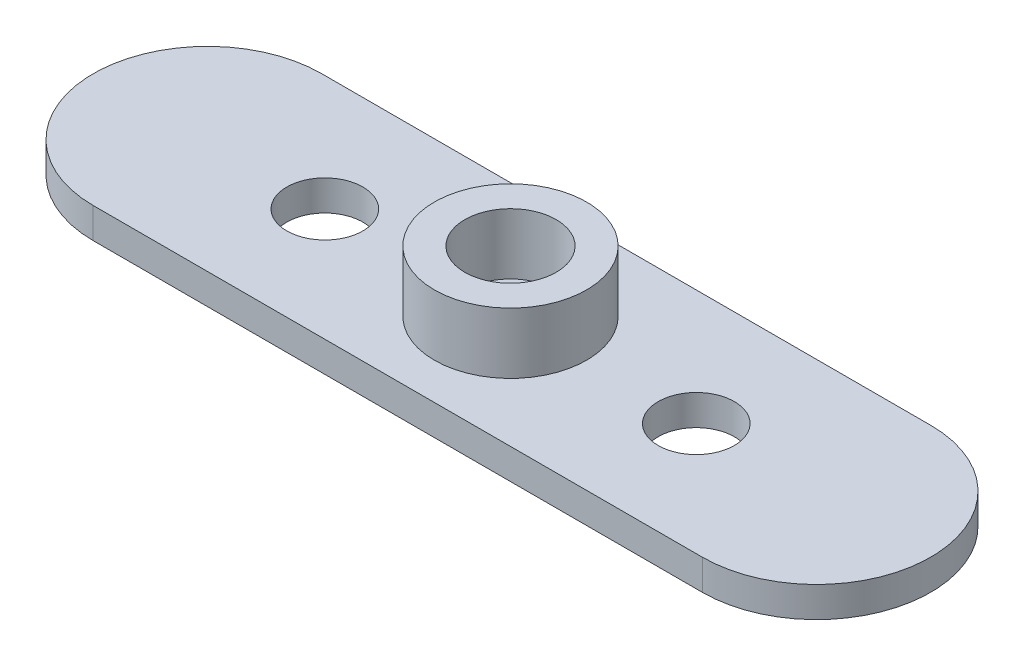
from build123d import *

# Parameters (mm, degrees)
BOSS_EXTRUDE1_DEPTH = 2
SKETCH2_R           = 5
BOSS_EXTRUDE3_DEPTH = 4
SKETCH5_R           = 3
CUT_EXTRUDE1_DEPTH  = 4
SKETCH6_R           = 1.5
CUT_EXTRUDE2_DEPTH  = 2
SKETCH8_R           = 2.5
CUT_EXTRUDE3_DEPTH  = 3
SKETCH7_R           = 2.5
CUT_EXTRUDE4_DEPTH  = 3


with BuildPart() as part:
    # Sketch1 → Boss-Extrude1 (new body)
    with BuildSketch(Plane(origin=(0, 0, 0), x_dir=(1, 0, 0), z_dir=(0, 1, 0))):
        with BuildLine():
            Line((-20, 7.598649923), (20, 7.598649923))
            ThreePointArc((20, 7.598649923), (27.5, 0.098649923), (20, -7.401350077))
            Line((20, -7.401350077), (-20, -7.401350077))
            ThreePointArc((-20, -7.401350077), (-27.5, 0.098649923), (-20, 7.598649923))
        make_face()
    extrude(amount=BOSS_EXTRUDE1_DEPTH)

    # Sketch2 → Boss-Extrude3 (add)
    with BuildSketch(Plane(origin=(0, 2, 0), x_dir=(1, 0, 0), z_dir=(0, 1, 0))):
        Circle(SKETCH2_R)
    extrude(amount=BOSS_EXTRUDE3_DEPTH)

    # Sketch5 → Cut-Extrude1 (cut)
    with BuildSketch(Plane(origin=(0, 6, 0), x_dir=(1, 0, 0), z_dir=(0, 1, 0))):
        Circle(SKETCH5_R)
    extrude(amount=-CUT_EXTRUDE1_DEPTH, mode=Mode.SUBTRACT)

    # Sketch6 → Cut-Extrude2 (cut)
    with BuildSketch(Plane(origin=(0, 2, 0), x_dir=(1, 0, 0), z_dir=(0, 1, 0))):
        Circle(SKETCH6_R)
    extrude(amount=-CUT_EXTRUDE2_DEPTH, mode=Mode.SUBTRACT)

    # Sketch8 → Cut-Extrude3 (cut, through all)
    with BuildSketch(Plane(origin=(0, 2, 0), x_dir=(1, 0, 0), z_dir=(0, 1, 0))):
        with Locations((-12.2, 0.009046723)):
            Circle(SKETCH8_R)
    extrude(amount=-CUT_EXTRUDE3_DEPTH, mode=Mode.SUBTRACT)

    # Sketch7 → Cut-Extrude4 (cut, through all)
    with BuildSketch(Plane(origin=(0, 2, 0), x_dir=(1, 0, 0), z_dir=(0, 1, 0))):
        with Locations((12.2, 0)):
            Circle(SKETCH7_R)
    extrude(amount=-CUT_EXTRUDE4_DEPTH, mode=Mode.SUBTRACT)


solid = part.part
